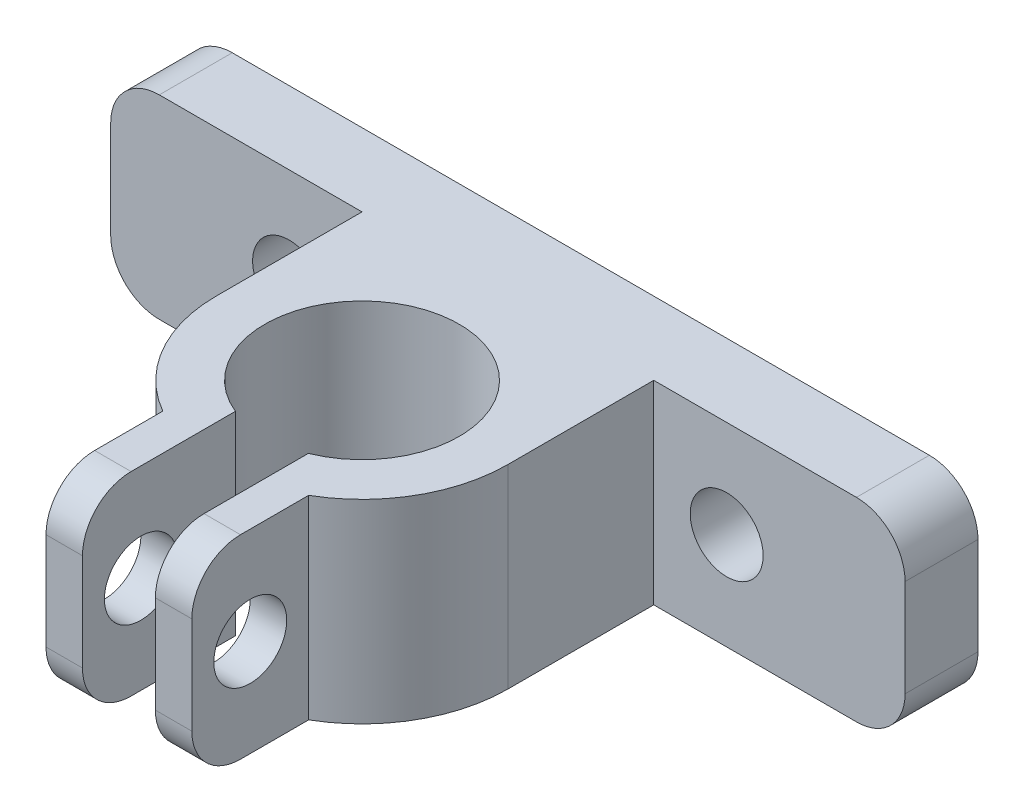
from build123d import *

# Parameters (mm, degrees)
SKETCH_1_W          = 32.677388302
SKETCH_1_H          = 8
EXTRUDE_1_DEPTH     = 3
SKETCH_2_R          = 1.5
CUT_EXTRUDE_1_DEPTH = 4
SKETCH_3_R          = 6
EXTRUDE_2_DEPTH     = 8
SKETCH_4_R          = 4
CUT_EXTRUDE_2_DEPTH = 9
EXTRUDE_3_DEPTH     = 8
SKETCH_6_W          = 6
SKETCH_6_H          = 6
EXTRUDE_4_DEPTH     = 8
SKETCH_8_W          = 3
SKETCH_8_H          = 10.466633743
CUT_EXTRUDE_5_DEPTH = 9
SKETCH_9_R          = 1.5
CUT_EXTRUDE_6_DEPTH = 20.338694151
FILLET_1_R          = 2
FILLET_2_R          = 2


with BuildPart() as part:
    # 草图1 → 凸台-拉伸1 (new body)
    with BuildSketch(Plane.XY):
        with Locations((-3.726697353, 26.358574689)):
            Rectangle(SKETCH_1_W, SKETCH_1_H)
    extrude(amount=-EXTRUDE_1_DEPTH)

    # 草图2 → 切除-拉伸1 (cut, through all)
    with BuildSketch(Plane.XY):
        with Locations((-12.726697353, 26.358574689)):
            Circle(SKETCH_2_R)
        with Locations((5.273302647, 26.358574689)):
            Circle(SKETCH_2_R)
    extrude(amount=-CUT_EXTRUDE_1_DEPTH, mode=Mode.SUBTRACT)



with BuildPart() as body_2:
    # 草图3 → 凸台-拉伸2 (new body)
    with BuildSketch(Plane.XZ.offset(-22.358574689)):
        with Locations((-3.726697353, 6)):
            Circle(SKETCH_3_R)
    extrude(amount=-EXTRUDE_2_DEPTH)

    # 草图4 → 切除-拉伸2 (cut, through all)
    with BuildSketch(Plane.XZ.offset(-22.358574689)):
        with Locations((-3.726697353, 6)):
            Circle(SKETCH_4_R)
    extrude(amount=-CUT_EXTRUDE_2_DEPTH, mode=Mode.SUBTRACT)


with BuildPart() as part_1:
    add(part.part)

    add(body_2.part)  # 凸台-拉伸3 merges body 2
    # 草图5 → 凸台-拉伸3 (add)
    with BuildSketch(Plane.XZ.offset(-22.358574689)):
        Polygon((-3.726697353, 0), (-9.726697353, 6), (-9.726697353, 0), align=None)
        Polygon((2.273302647, 6), (-3.726697353, 0), (2.273302647, 0), align=None)
    extrude(amount=-EXTRUDE_3_DEPTH)

    # 草图6 → 凸台-拉伸4 (add)
    with BuildSketch(Plane.XZ.offset(-22.358574689)):
        with Locations((-3.726697353, 13)):
            Rectangle(SKETCH_6_W, SKETCH_6_H)
    extrude(amount=-EXTRUDE_4_DEPTH)

    # 草图8 → 切除-拉伸5 (cut, through all)
    with BuildSketch(Plane.XZ.offset(-22.358574689)):
        with Locations((-3.726697353, 11.233316872)):
            Rectangle(SKETCH_8_W, SKETCH_8_H)
    extrude(amount=-CUT_EXTRUDE_5_DEPTH, mode=Mode.SUBTRACT)

    # 草图9 → 切除-拉伸6 (cut, through all)
    with BuildSketch(Plane(origin=(-0.726697353, 0, 0), x_dir=(0, 0, -1), z_dir=(1, 0, 0))):
        with Locations((-13.598076211, 26.358574689)):
            Circle(SKETCH_9_R)
    extrude(amount=-CUT_EXTRUDE_6_DEPTH, mode=Mode.SUBTRACT)

    # 圆角1
    fillet_1_edges = [part_1.edges().sort_by_distance(p)[0] for p in [
        (12.611996798, 22.358574689, -1.5),
        (-20.065391504, 22.358574689, -1.5),
        (-20.065391504, 30.358574689, -1.5),
        (12.611996798, 30.358574689, -1.5),
    ]]
    fillet(fillet_1_edges, radius=FILLET_1_R)

    # 圆角2
    fillet_2_edges = [part_1.edges().sort_by_distance(p)[0] for p in [
        (-1.476697353, 22.358574689, 16),
        (-1.476697353, 30.358574689, 16),
        (-5.976697353, 30.358574689, 16),
        (-5.976697353, 22.358574689, 16),
    ]]
    fillet(fillet_2_edges, radius=FILLET_2_R)


solid = part_1.part
